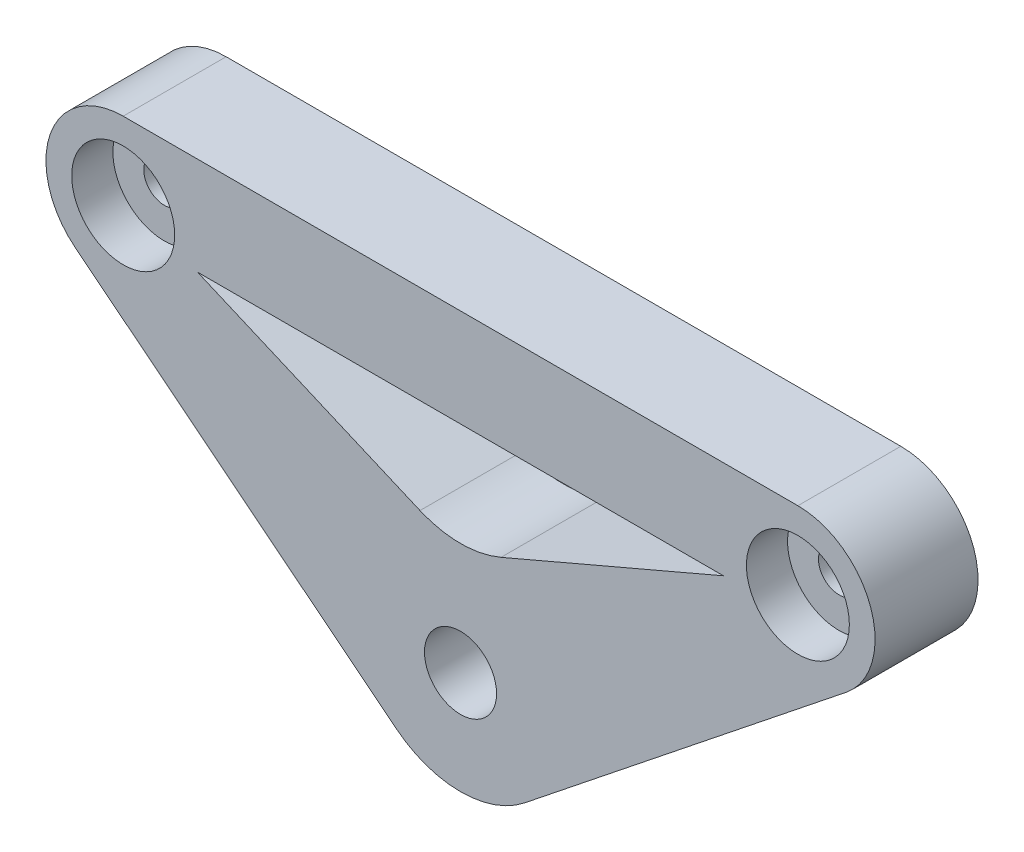
from build123d import *

# Parameters (mm, degrees)
SKETCH1_R           = 3.5
SKETCH1_R_2         = 2
BOSS_EXTRUDE1_DEPTH = 10
FILLET1_R           = 10
SKETCH2_R           = 6.5
CUT_EXTRUDE1_DEPTH  = 5
SKETCH3_R           = 5
CUT_EXTRUDE2_DEPTH  = 4


with BuildPart() as part:
    # Sketch1 → Boss-Extrude1 (new body)
    with BuildSketch(Plane.XY):
        with BuildLine():
            Line((-37.443472345, 17.080292115), (-6.236520765, -7.817020452))
            ThreePointArc((-6.236520765, -7.817020452), (0, -10), (6.236520765, -7.817020452))
            Line((6.236520765, -7.817020452), (37.443472345, 17.080292115))
            ThreePointArc((37.443472345, 17.080292115), (39.84494962, 25.420885127), (32.766081772, 30.443057454))
            Line((32.766081772, 30.443057454), (-32.766081772, 30.443057454))
            ThreePointArc((-32.766081772, 30.443057454), (-39.84494962, 25.420885127), (-37.443472345, 17.080292115))
        make_face()
        Polygon((25.540228058, 20.933819261), (0, 10), (-25.540228058, 20.933819261), align=None, mode=Mode.SUBTRACT)
        Circle(SKETCH1_R, mode=Mode.SUBTRACT)
        with Locations((-32.766081772, 22.943057454)):
            Circle(SKETCH1_R_2, mode=Mode.SUBTRACT)
        with Locations((32.766081772, 22.943057454)):
            Circle(SKETCH1_R_2, mode=Mode.SUBTRACT)
    extrude(amount=BOSS_EXTRUDE1_DEPTH)

    # Fillet1
    fillet1_edges = [part.edges().sort_by_distance(p)[0] for p in [
        (0, 10, 5),
    ]]
    fillet(fillet1_edges, radius=FILLET1_R)

    # Sketch2 → Cut-Extrude1 (cut)
    with BuildSketch(Plane(origin=(0, 0, 0), x_dir=(-1, 0, 0), z_dir=(0, 0, -1))):
        Circle(SKETCH2_R)
    extrude(amount=-CUT_EXTRUDE1_DEPTH, mode=Mode.SUBTRACT)

    # Sketch3 → Cut-Extrude2 (cut)
    with BuildSketch(Plane.XY.offset(10)):
        with Locations((-32.766081772, 22.943057454)):
            Circle(SKETCH3_R)
        with Locations((32.766081772, 22.943057454)):
            Circle(SKETCH3_R)
    extrude(amount=-CUT_EXTRUDE2_DEPTH, mode=Mode.SUBTRACT)


solid = part.part
